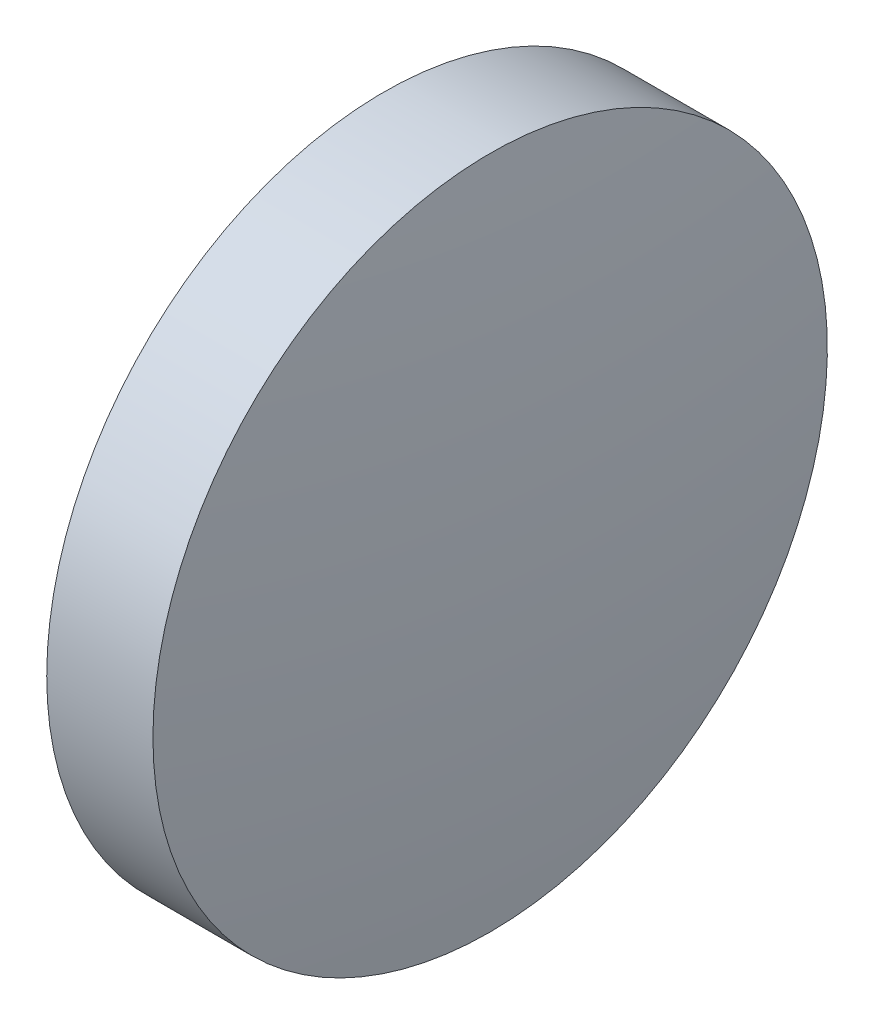
from build123d import *


with BuildPart() as part:
    # 草图2 → 旋转2 (revolve)
    with BuildSketch(Plane.XY, mode=Mode.PRIVATE) as revolve_2_sk:
        with BuildLine():
            Line((551.812570364, 54.827479991), (551.812570364, 61.177479991))
            Line((551.812570364, 61.177479991), (553.812570364, 61.177479991))
            ThreePointArc((553.812570364, 61.177479991), (554.112471361, 58.008772967), (554.212570364, 54.827479991))
            Line((554.212570364, 54.827479991), (551.812570364, 54.827479991))
        make_face()
    revolve(revolve_2_sk.sketch.rotate(Axis((549.552039219, 54.827479991, 0), (1, 0, 0)), 180), axis=Axis((549.552039219, 54.827479991, 0), (1, 0, 0)))  # turned: the seam where the file's is


solid = part.part
